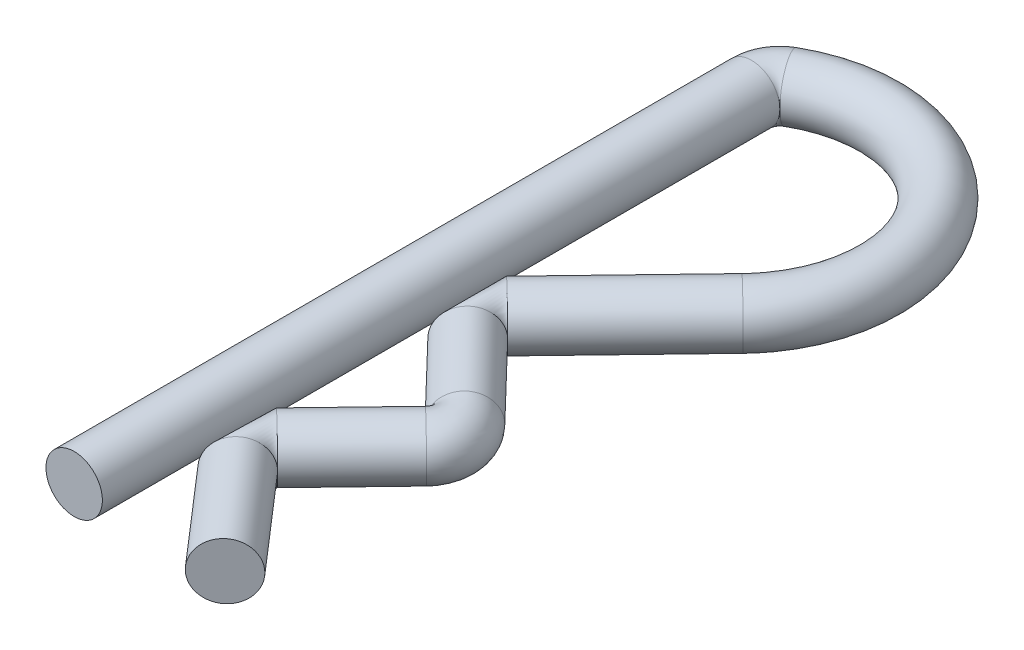
from build123d import *

# Parameters (mm, degrees)
SWEEP1_PROFILE_R = 0.5


with BuildPart() as part:
    # Sweep1: sweep along a path in Sketch1
    with BuildLine(Plane(origin=(0, 0, 0), x_dir=(1, 0, 0), z_dir=(0, 1, 0))) as sweep1_path:
        Line((0, 0), (0, 12))
        ThreePointArc((0, 12), (0.066987298, 12.25), (0.25, 12.433012702))
        ThreePointArc((0.25, 12.433012702), (3.468532099, 11.809014206), (3.301717186, 8.534797387))
        Line((3.301717186, 8.534797387), (1.256503297, 6.408672599))
        ThreePointArc((1.256503297, 6.408672599), (1.116846734, 6.062042238), (1.256503297, 5.715411877))
        Line((1.256503297, 5.715411877), (2.53340759, 4.387991853))
        ThreePointArc((2.53340759, 4.387991853), (2.673064153, 4.041361492), (2.53340759, 3.694731131))
        Line((2.53340759, 3.694731131), (1.239485824, 2.349620405))
        ThreePointArc((1.239485824, 2.349620405), (1.1, 2.016055627), (1.221868411, 1.675659025))
        Line((1.221868411, 1.675659025), (2.673064153, 0))
    # Sweep1 profile (on start of the path) → Sweep1 (sweep)
    with BuildSketch(Plane(origin=(0, 0, 0), x_dir=(-1, 0, 0), z_dir=(0, 0, -1))):
        Circle(SWEEP1_PROFILE_R)
    sweep(path=sweep1_path.line)


solid = part.part
